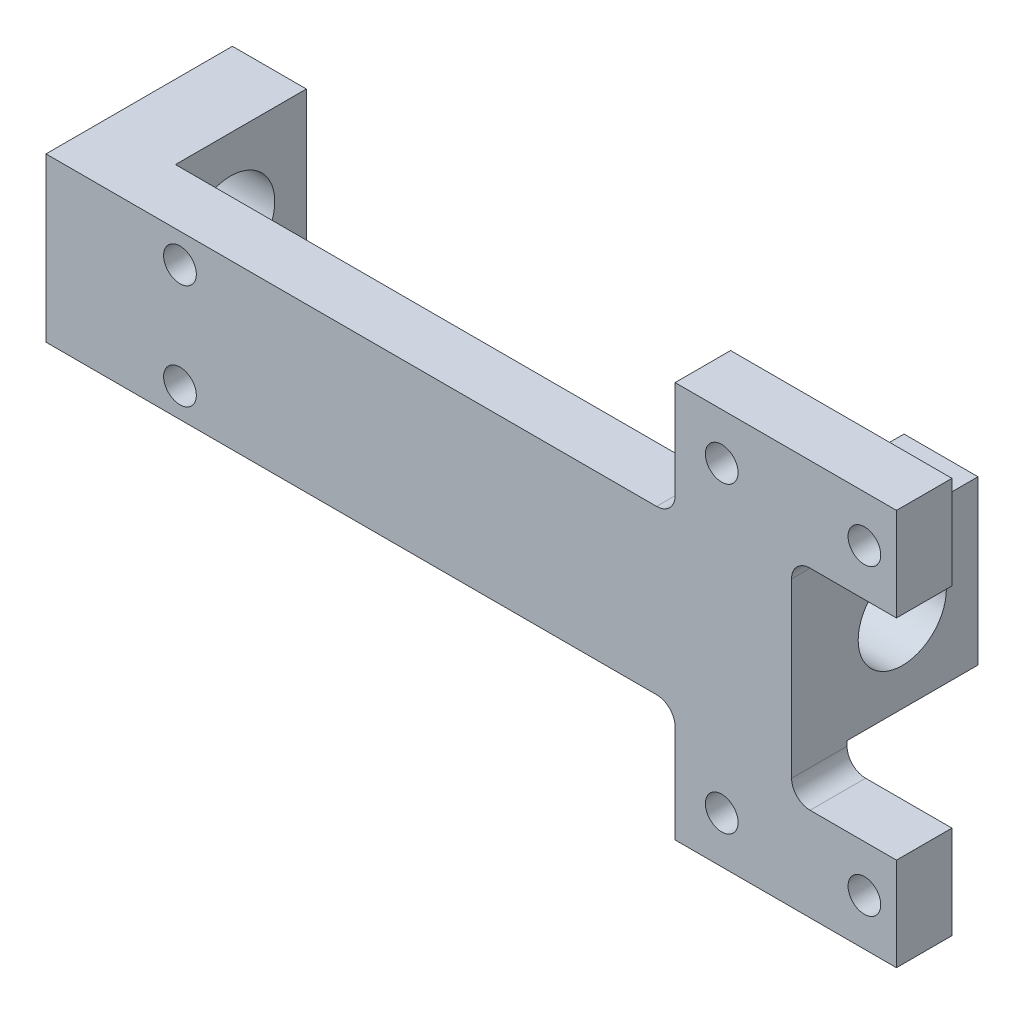
from build123d import *

# Parameters (mm, degrees)
SKETCH1_W                  = 32
SKETCH1_H                  = 28
SKETCH1_R                  = 7.5692
BOSS_EXTRUDE1_DEPTH        = 64
SKETCH5_W                  = 102.6
SKETCH5_H                  = 28
CUT_EXTRUDE1_DEPTH         = 9.475
CUT_EXTRUDE1_DEPTH_BACK    = 33.147
F_10_CLEARANCE_HOLE1_D     = 5.6134
F_10_CLEARANCE_HOLE1_DEPTH = 25.4
F_10_CLEARANCE_HOLE1_TIP   = 1.686435499
BOSS_EXTRUDE2_DEPTH        = 9.525
F_10_CLEARANCE_HOLE2_D     = 5.6134
FILLET2_R                  = 3.175


with BuildPart() as part:
    # Sketch1 → Boss-Extrude1 (new body, symmetric)
    with BuildSketch(Plane(origin=(0, 0, 0), x_dir=(0, 0, -1), z_dir=(1, 0, 0))):
        with Locations((-3, 0)):
            Rectangle(SKETCH1_W, SKETCH1_H)
        Circle(SKETCH1_R, mode=Mode.SUBTRACT)
    extrude(amount=BOSS_EXTRUDE1_DEPTH, both=True)

    # Sketch5 → Cut-Extrude1 (cut, two sides)
    with BuildSketch(Plane.XY) as cut_extrude1_sk:
        Rectangle(SKETCH5_W, SKETCH5_H)
    extrude(amount=CUT_EXTRUDE1_DEPTH, mode=Mode.SUBTRACT)
    extrude(cut_extrude1_sk.sketch, amount=-CUT_EXTRUDE1_DEPTH_BACK, mode=Mode.SUBTRACT)

    # #10 Clearance Hole1
    with Locations(Plane(origin=(-39.55789498, -3.670822781, 9.475), x_dir=(-1, 0, 0), z_dir=(0, 0, -1))):
        with Locations((1.44210502, -5.329177219), (1.44210502, 12.670822781)):
            Hole(F_10_CLEARANCE_HOLE1_D / 2, depth=F_10_CLEARANCE_HOLE1_DEPTH)
            with Locations((0, 0, -(F_10_CLEARANCE_HOLE1_DEPTH + F_10_CLEARANCE_HOLE1_TIP / 2))):  # 118° drill point
                Cone(0, F_10_CLEARANCE_HOLE1_D / 2, F_10_CLEARANCE_HOLE1_TIP, mode=Mode.SUBTRACT)

    # Sketch7 → Boss-Extrude2 (add)
    with BuildSketch(Plane(origin=(0, 0, 9.475), x_dir=(-1, 0, 0), z_dir=(0, 0, -1))):
        Polygon((-44, -14), (-64, -14), (-64, -18), (-82, -18), (-82, -34), (-44, -34), align=None)
    boss_extrude2 = extrude(amount=-BOSS_EXTRUDE2_DEPTH)

    # #10 Clearance Hole2 (through all)
    with Locations(Plane(origin=(0, 0, 9.475), x_dir=(-1, 0, 0), z_dir=(0, 0, -1))):
        with Locations((-76.5, -26), (-52, -26)):
            f_10_clearance_hole2 = Hole(F_10_CLEARANCE_HOLE2_D / 2)

    # Mirror2: Boss-Extrude2, #10 Clearance Hole2 across plane
    add(boss_extrude2.mirror(Plane.ZX))
    add(f_10_clearance_hole2.mirror(Plane.ZX), mode=Mode.SUBTRACT)

    # Fillet2
    fillet2_edges = [part.edges().sort_by_distance(p)[0] for p in [
        (44, 14, 14.2375),
        (44, -14, 14.2375),
        (64, 18, 14.2375),
        (64, -18, 14.2375),
    ]]
    fillet(fillet2_edges, radius=FILLET2_R)


solid = part.part
